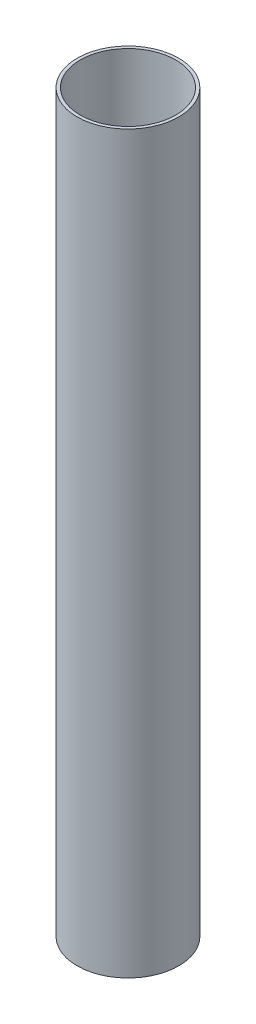
from build123d import *

# Parameters (mm, degrees)
SKETCH1_W = 3.175
SKETCH1_H = 762


with BuildPart() as part:
    # Sketch1 → Revolve1 (revolve)
    with BuildSketch(Plane.XY):
        with Locations((51.1175, 381)):
            Rectangle(SKETCH1_W, SKETCH1_H)
    revolve(axis=Axis((0, 797.913336974, 0), (0, -1, 0)))


solid = part.part
